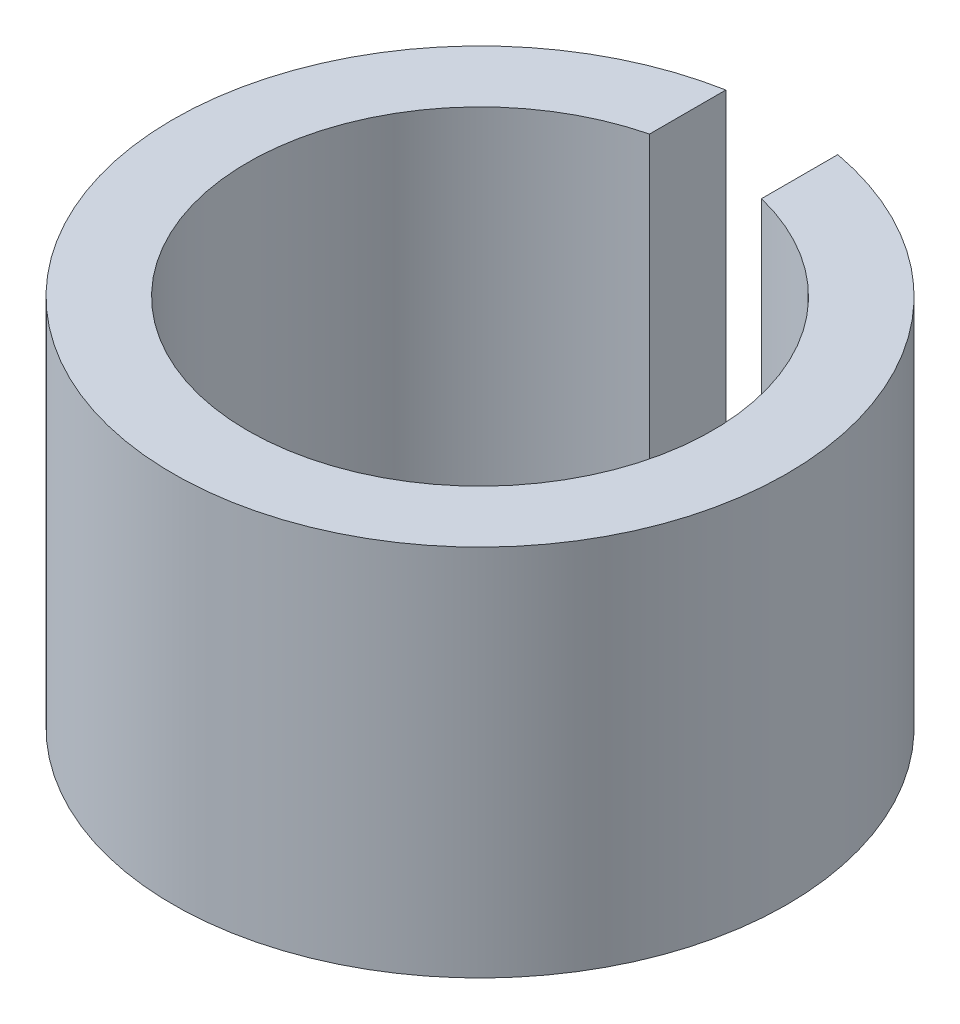
from build123d import *

# Parameters (mm, degrees)
BOSS_EXTRUDE1_DEPTH = 5.08


with BuildPart() as part:
    # Sketch1 → Boss-Extrude1 (new body)
    with BuildSketch(Plane(origin=(0, 0, 0), x_dir=(1, 0, 0), z_dir=(0, 1, 0))):
        with BuildLine():
            Line((-0.762, 4.108229167), (-0.762, 3.069119954))
            ThreePointArc((-0.762, 3.069119954), (0, -3.1623), (0.762, 3.069119954))
            Line((0.762, 3.069119954), (0.762, 4.108229167))
            ThreePointArc((0.762, 4.108229167), (0, -4.1783), (-0.762, 4.108229167))
        make_face()
    extrude(amount=BOSS_EXTRUDE1_DEPTH)


solid = part.part
